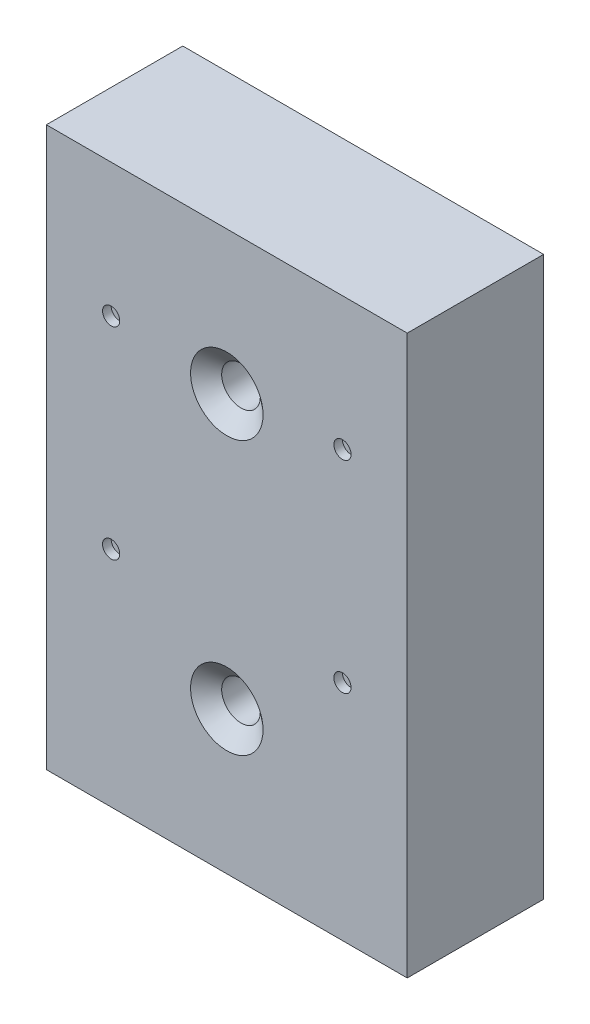
from build123d import *

# Parameters (mm, degrees)
SKETCH1_W                                         = 42
SKETCH1_H                                         = 65
BOSS_EXTRUDE1_DEPTH                               = 15.875
SKETCH2_R                                         = 1
CUT_EXTRUDE1_DEPTH                                = 1
CUT_EXTRUDE1_DEPTH_BACK                           = 1
CSK_FOR_8_FLAT_HEAD_MACHINE_SCREW_100_D           = 4.4958
CSK_FOR_8_FLAT_HEAD_MACHINE_SCREW_100_CSINK_D     = 8.4328
CSK_FOR_8_FLAT_HEAD_MACHINE_SCREW_100_CSINK_ANGLE = 100


with BuildPart() as part:
    # Sketch1 → Boss-Extrude1 (new body)
    with BuildSketch(Plane.XY):
        Rectangle(SKETCH1_W, SKETCH1_H)
    extrude(amount=BOSS_EXTRUDE1_DEPTH)

    # Sketch2 → Cut-Extrude1 (cut, two sides)
    with BuildSketch(Plane.XY.offset(15.875)) as cut_extrude1_sk:
        with Locations((-13.459539776, -6.5)):
            Circle(SKETCH2_R)
        with Locations((-13.459539776, 17)):
            Circle(SKETCH2_R)
        with Locations((13.459539776, 17)):
            Circle(SKETCH2_R)
        with Locations((13.459539776, -6.5)):
            Circle(SKETCH2_R)
    extrude(amount=CUT_EXTRUDE1_DEPTH, mode=Mode.SUBTRACT)
    extrude(cut_extrude1_sk.sketch, amount=-CUT_EXTRUDE1_DEPTH_BACK, mode=Mode.SUBTRACT)

    # CSK for #8 Flat Head Machine Screw (100)1 (through all)
    with Locations(Plane.XY.offset(15.875)):
        with Locations((0, 15.875), (0, -15.875)):
            CounterSinkHole(CSK_FOR_8_FLAT_HEAD_MACHINE_SCREW_100_D / 2, CSK_FOR_8_FLAT_HEAD_MACHINE_SCREW_100_CSINK_D / 2, counter_sink_angle=CSK_FOR_8_FLAT_HEAD_MACHINE_SCREW_100_CSINK_ANGLE)


solid = part.part
